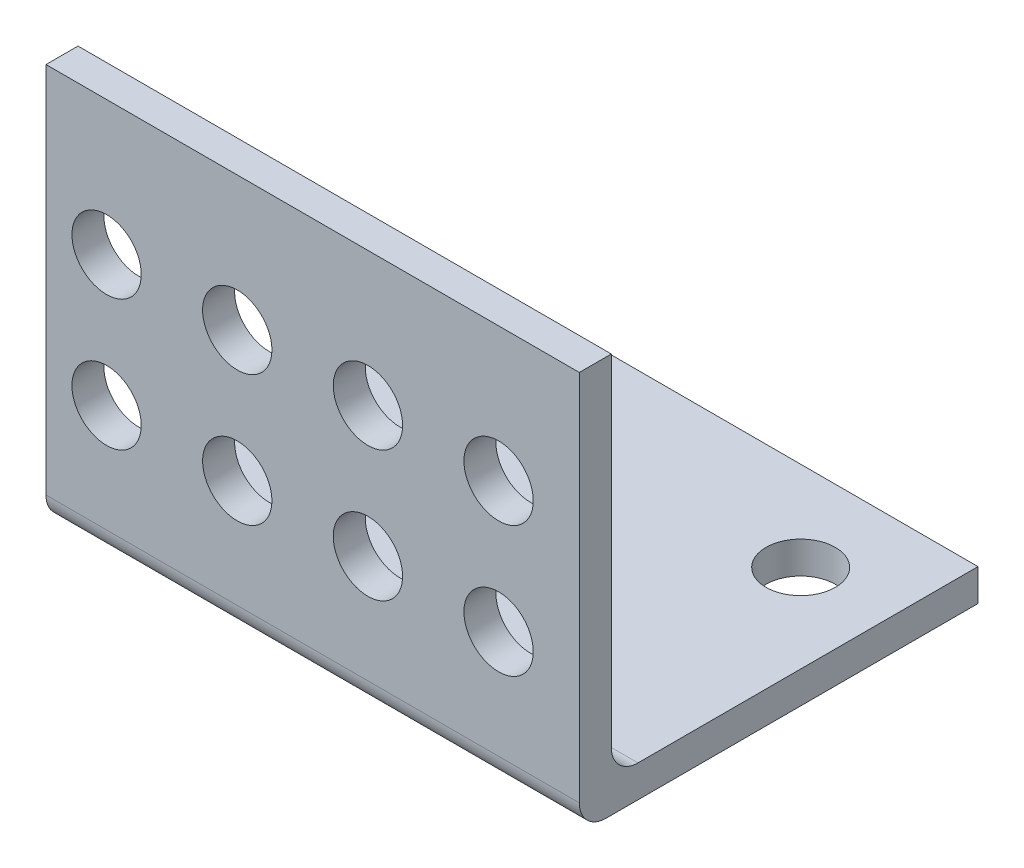
from build123d import *

# Parameters (mm, degrees)
BOSS_EXTRUDE2_DEPTH = 40
SKETCH1_R           = 2.6
CUT_EXTRUDE4_DEPTH  = 40
SKETCH5_R           = 2.6
CUT_EXTRUDE5_DEPTH  = 40


with BuildPart() as part:
    # Sketch3 → Boss-Extrude2 (new body)
    with BuildSketch(Plane(origin=(0, 0, 0), x_dir=(0, 0, -1), z_dir=(1, 0, 0))):
        with BuildLine():
            Line((2, -17.949216757), (29.9, -17.949216757))
            Line((29.9, -17.949216757), (29.9, -15.549216757))
            Line((29.9, -15.549216757), (4.4, -15.549216757))
            ThreePointArc((4.4, -15.549216757), (2.985786438, -14.963430319), (2.4, -13.549216757))
            Line((2.4, -13.549216757), (2.4, 12.010783243))
            Line((2.4, 12.010783243), (0, 12.010783243))
            Line((0, 12.010783243), (0, -15.949216757))
            ThreePointArc((0, -15.949216757), (0.585786438, -17.363430319), (2, -17.949216757))
        make_face()
    extrude(amount=-BOSS_EXTRUDE2_DEPTH)

    # Sketch1 → Cut-Extrude4 (cut)
    with BuildSketch(Plane.XY):
        with Locations((-35.455799348, 1.940783243)):
            Circle(SKETCH1_R)
        with Locations((-25.655799348, 1.940783243)):
            Circle(SKETCH1_R)
        with Locations((-15.855799348, 1.940783243)):
            Circle(SKETCH1_R)
        with Locations((-6.055799348, 1.940783243)):
            Circle(SKETCH1_R)
        with Locations(Location((-6.055799348, -7.859216757, 0), (0, 0, 180))):  # turned: the seam where the file's is
            Circle(SKETCH1_R)
        with Locations(Location((-15.855799348, -7.859216757, 0), (0, 0, 180))):  # turned: the seam where the file's is
            Circle(SKETCH1_R)
        with Locations(Location((-25.655799348, -7.859216757, 0), (0, 0, 180))):  # turned: the seam where the file's is
            Circle(SKETCH1_R)
        with Locations(Location((-35.455799348, -7.859216757, 0), (0, 0, 180))):  # turned: the seam where the file's is
            Circle(SKETCH1_R)
    extrude(amount=-CUT_EXTRUDE4_DEPTH, mode=Mode.SUBTRACT)

    # Sketch5 → Cut-Extrude5 (cut)
    with BuildSketch(Plane(origin=(0, -15.549216757, 0), x_dir=(1, 0, 0), z_dir=(0, 1, 0))):
        with Locations(Location((-33.4, 23.2, 0), (0, 0, 270))):  # turned: the seam where the file's is
            Circle(SKETCH5_R)
        with Locations(Location((-6.6, 23.2, 0), (0, 0, 90))):  # turned: the seam where the file's is
            Circle(SKETCH5_R)
        with Locations(Location((-20, 13.2, 0), (0, 0, 270))):  # turned: the seam where the file's is
            Circle(SKETCH5_R)
    extrude(amount=-CUT_EXTRUDE5_DEPTH, mode=Mode.SUBTRACT)


solid = part.part
